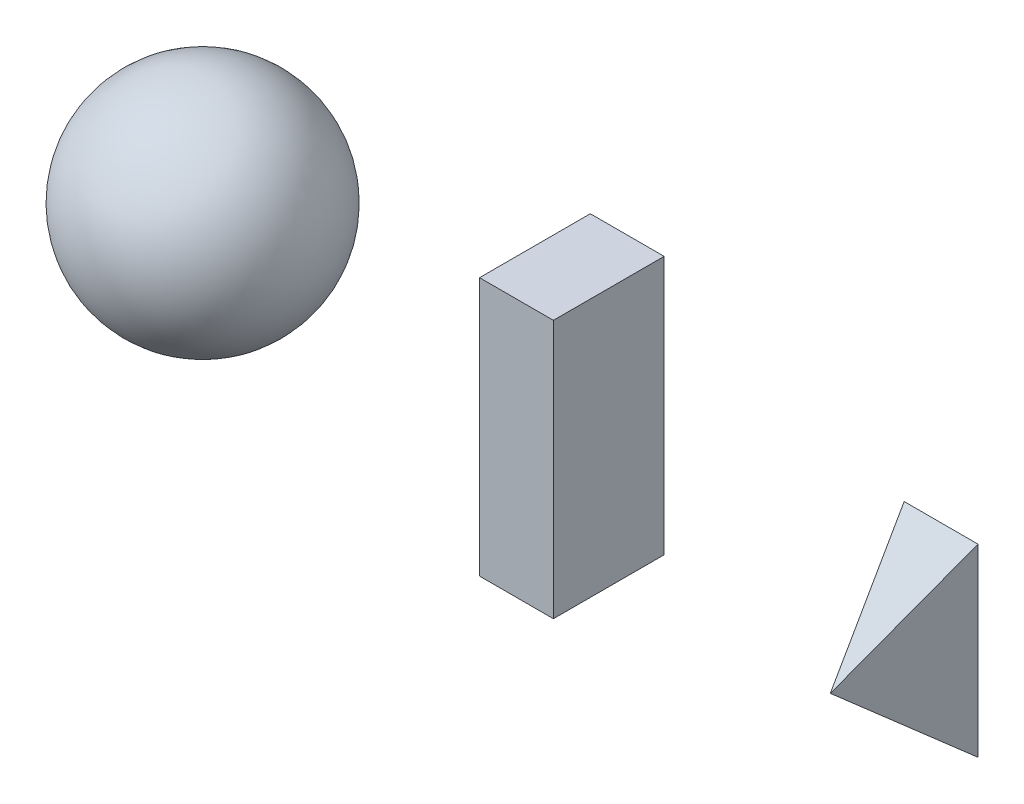
from build123d import *

# Parameters (mm, degrees)
SKETCH1_W                       = 50.8
SKETCH1_H                       = 177.8
RECPRISM_DEPTH                  = 38.1
PYRAMIDBASE_W                   = 50.8
PYRAMIDBASE_H                   = 127
PYRAMID_DEPTH                   = 76.2
SKETCH5_OUTSIDE_W               = 380.984
SKETCH5_OUTSIDE_H               = 190.484
CUT_EXTRUDE_PYRAMIDY_DEPTH      = 89.9
CUT_EXTRUDE_PYRAMIDY_DEPTH_BACK = 89.9
SKETCH6_OUTSIDE_W               = 190.484
SKETCH6_OUTSIDE_H               = 253.984
CUT_EXTRUDE_PYRAMIDX_DEPTH      = 26.4
CUT_EXTRUDE_PYRAMIDX_DEPTH_BACK = 280.4


with BuildPart() as part:
    # Sketch1 → RecPrism (new body, symmetric)
    with BuildSketch(Plane.XY):
        Rectangle(SKETCH1_W, SKETCH1_H)
    extrude(amount=RECPRISM_DEPTH, both=True)


with BuildPart() as body_2:
    # PyramidBase → Pyramid (new body)
    with BuildSketch(Plane.XY):
        with Locations((254, 0)):
            Rectangle(PYRAMIDBASE_W, PYRAMIDBASE_H)
    extrude(amount=PYRAMID_DEPTH)

    # Sketch5 outside → Cut-Extrude_PyramidY (cut, two sides)
    with BuildSketch(Plane(origin=(0, 0, 0), x_dir=(1, 0, 0), z_dir=(0, 1, 0))) as cut_extrude_pyramidy_sk:
        with Locations((127, -19.05)):
            Rectangle(SKETCH5_OUTSIDE_W, SKETCH5_OUTSIDE_H)
        Polygon((279.4, 0), (254, -76.2), (228.6, 0), align=None, mode=Mode.SUBTRACT)
    extrude(amount=CUT_EXTRUDE_PYRAMIDY_DEPTH, mode=Mode.SUBTRACT)
    extrude(cut_extrude_pyramidy_sk.sketch, amount=-CUT_EXTRUDE_PYRAMIDY_DEPTH_BACK, mode=Mode.SUBTRACT)

    # Sketch6 outside → Cut-Extrude_PyramidX (cut, two sides)
    with BuildSketch(Plane(origin=(254, 0, 0), x_dir=(0, 0, -1), z_dir=(1, 0, 0))) as cut_extrude_pyramidx_sk:
        with Locations((-19.05, 0)):
            Rectangle(SKETCH6_OUTSIDE_W, SKETCH6_OUTSIDE_H)
        Polygon((-76.2, 0), (0, 63.5), (0, -63.5), align=None, mode=Mode.SUBTRACT)
    extrude(amount=CUT_EXTRUDE_PYRAMIDX_DEPTH, mode=Mode.SUBTRACT)
    extrude(cut_extrude_pyramidx_sk.sketch, amount=-CUT_EXTRUDE_PYRAMIDX_DEPTH_BACK, mode=Mode.SUBTRACT)


with BuildPart() as body_3:
    # Sphere → SphereRevolve (revolve)
    with BuildSketch(Plane.XY):
        with BuildLine():
            Line((-254, 76.2), (-254, 0))
            Line((-254, 0), (-254, -76.2))
            ThreePointArc((-254, -76.2), (-330.2, 0), (-254, 76.2))
        make_face()
    revolve(axis=Axis((-254, 76.2, 0), (0, -1, 0)))


solid = Compound([part.part, body_2.part, body_3.part])
